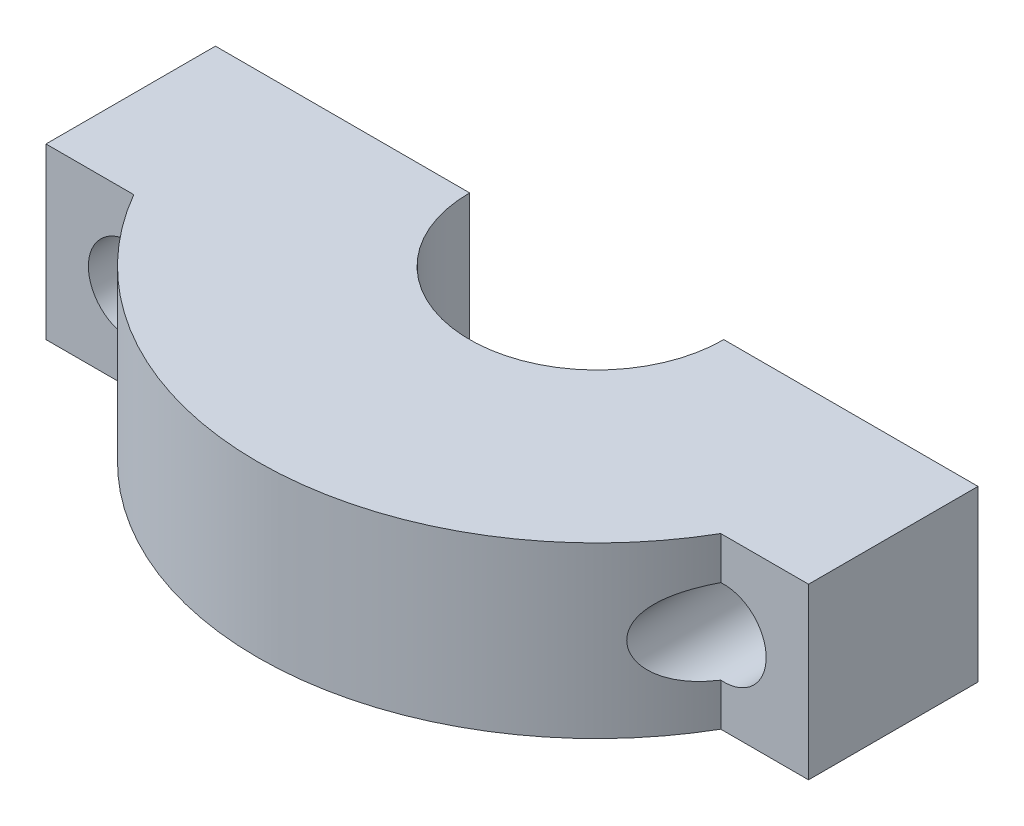
from build123d import *

# Parameters (mm, degrees)
BOSS_EXTRUDE1_DEPTH = 20
SKETCH2_R           = 5
CUT_EXTRUDE1_DEPTH  = 41


with BuildPart() as part:
    # Sketch1 → Boss-Extrude1 (new body)
    with BuildSketch(Plane(origin=(0, 0, 0), x_dir=(1, 0, 0), z_dir=(0, 1, 0))):
        with BuildLine():
            ThreePointArc((-34.641016151, -20), (-38.637033052, -10.352761804), (-40, 0))
            Line((-40, 0), (-45, 0))
            Line((-45, 0), (-45, -20))
            Line((-45, -20), (-34.641016151, -20))
        make_face()
        with BuildLine():
            Line((40, 0), (15, 0))
            ThreePointArc((15, 0), (0, -15), (-15, 0))
            Line((-15, 0), (-40, 0))
            ThreePointArc((-40, 0), (-38.637033052, -10.352761804), (-34.641016151, -20))
            Line((-34.641016151, -20), (34.641016151, -20))
            ThreePointArc((34.641016151, -20), (38.637033052, -10.352761804), (40, 0))
        make_face()
        with BuildLine():
            ThreePointArc((-34.641016151, -20), (0, -40), (34.641016151, -20))
            Line((34.641016151, -20), (-34.641016151, -20))
        make_face()
        with BuildLine():
            Line((45, 0), (40, 0))
            ThreePointArc((40, 0), (38.637033052, -10.352761804), (34.641016151, -20))
            Line((34.641016151, -20), (45, -20))
            Line((45, -20), (45, 0))
        make_face()
    extrude(amount=BOSS_EXTRUDE1_DEPTH)

    # Sketch2 → Cut-Extrude1 (cut, through all)
    with BuildSketch(Plane(origin=(0, 0, 0), x_dir=(-1, 0, 0), z_dir=(0, 0, -1))):
        with Locations((-35, 10)):
            Circle(SKETCH2_R)
        with Locations((35, 10)):
            Circle(SKETCH2_R)
    extrude(amount=-CUT_EXTRUDE1_DEPTH, mode=Mode.SUBTRACT)


solid = part.part
